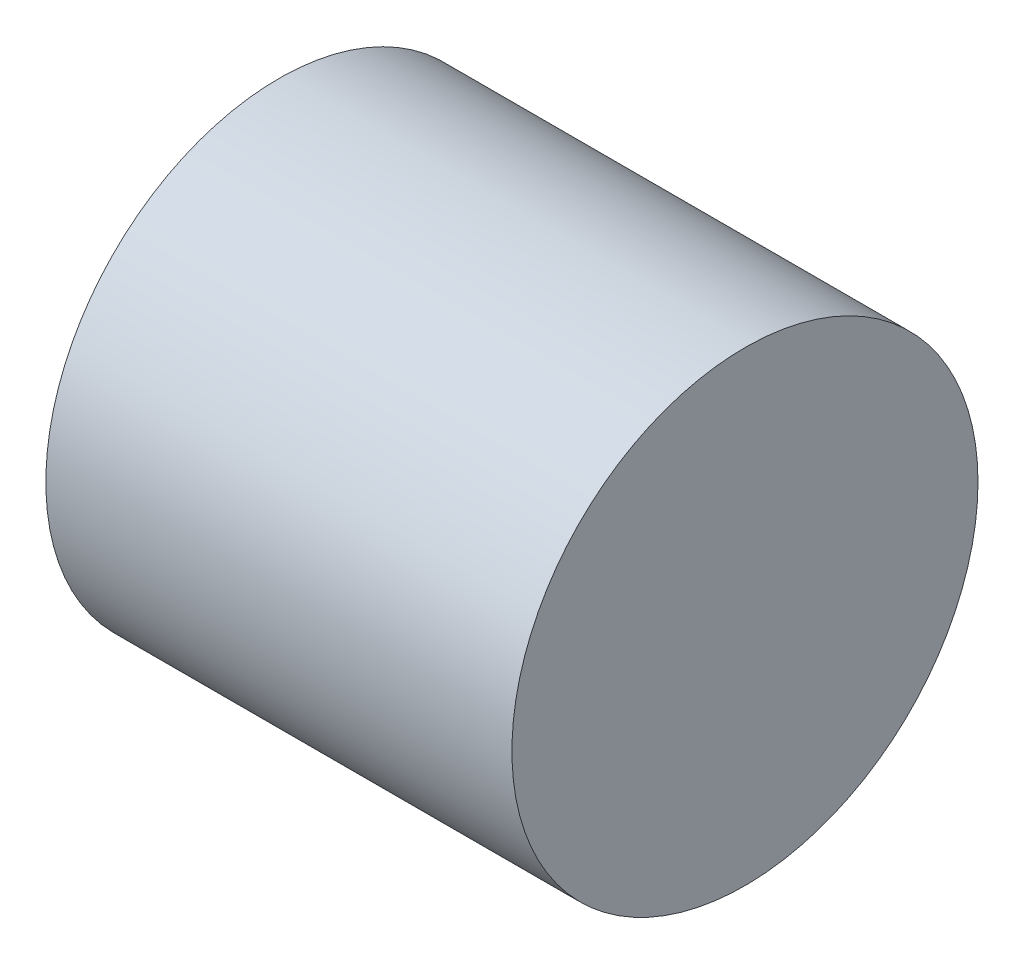
from build123d import *

# Parameters (mm, degrees)
SKETCH1_R           = 20
BOSS_EXTRUDE1_DEPTH = 40


with BuildPart() as part:
    # Sketch1 → Boss-Extrude1 (new body)
    with BuildSketch(Plane(origin=(0, 0, 0), x_dir=(0, 0, -1), z_dir=(1, 0, 0))):
        Circle(SKETCH1_R)
    extrude(amount=BOSS_EXTRUDE1_DEPTH)


solid = part.part
